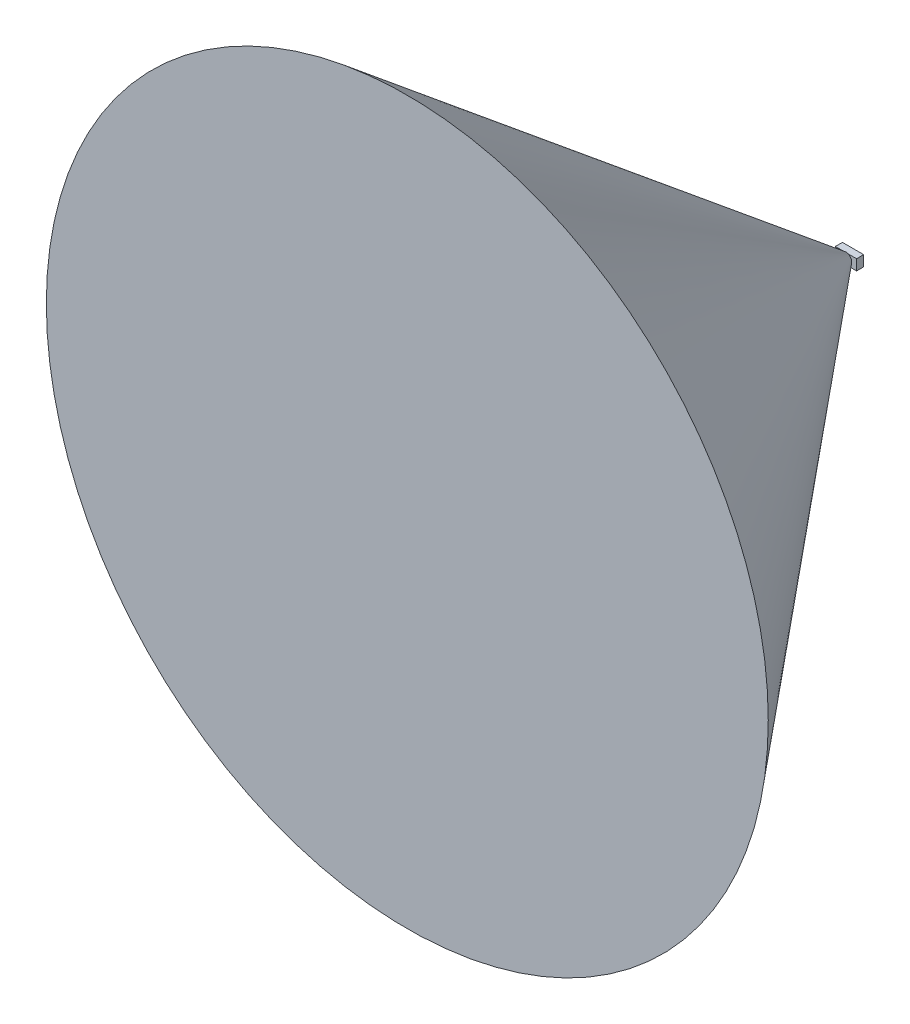
from build123d import *

# Parameters (mm, degrees)
SKETCH1_W           = 38.1
SKETCH1_H           = 19.05
BOSS_EXTRUDE1_DEPTH = 12.7


with BuildPart() as part:
    # Sketch1 → Boss-Extrude1 (new body)
    with BuildSketch(Plane.XY):
        Rectangle(SKETCH1_W, SKETCH1_H)
    extrude(amount=BOSS_EXTRUDE1_DEPTH)

    # Sketch2 → Revolve1 (revolve)
    with BuildSketch(Plane(origin=(0, 0, 0), x_dir=(0, 0, -1), z_dir=(1, 0, 0))):
        Polygon((0, 0), (-800, 647.827226556), (-800, 0), align=None)
    revolve(axis=Axis((0, 0, 800), (0, 0, -1)))


solid = part.part
